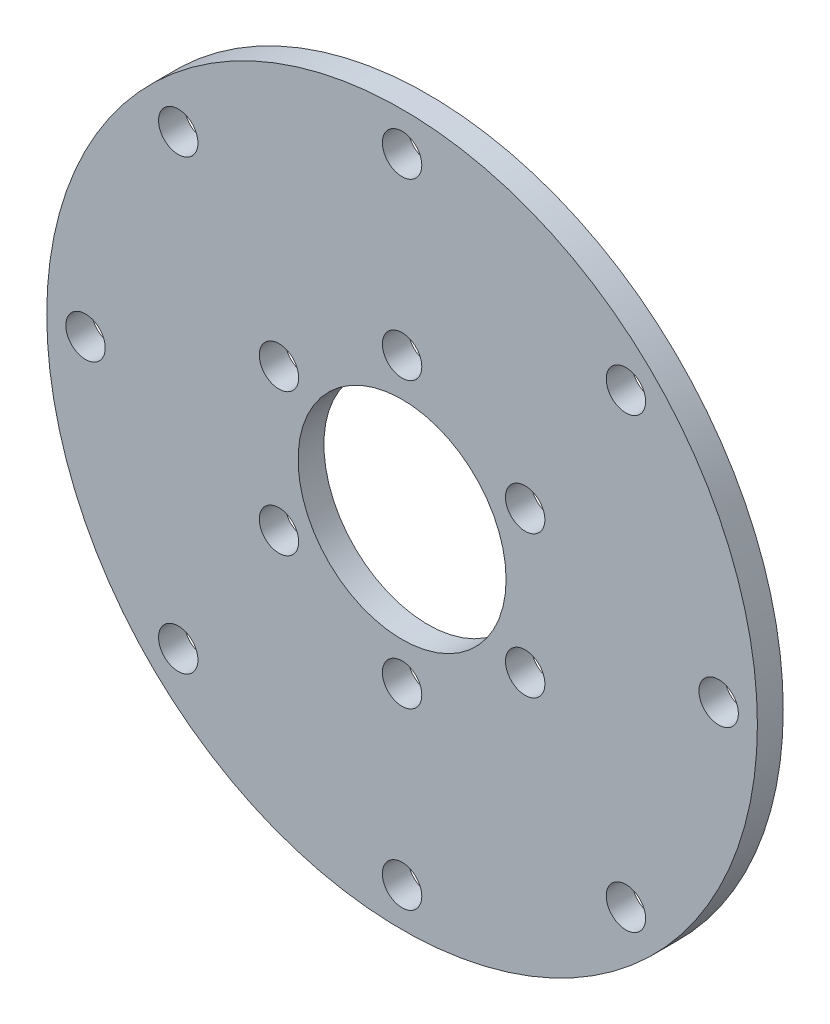
from build123d import *

# Parameters (mm, degrees)
SKETCH_1_R          = 27.5
SKETCH_1_R_2        = 8.05
EXTRUDE_1_DEPTH     = 2
SKETCH_2_R          = 1.525
CUT_EXTRUDE_1_DEPTH = 2
SKETCH_3_R          = 1.525
CUT_EXTRUDE_2_DEPTH = 2


with BuildPart() as part:
    # 草图1 → 凸台-拉伸1 (new body)
    with BuildSketch(Plane.XY):
        Circle(SKETCH_1_R)
        Circle(SKETCH_1_R_2, mode=Mode.SUBTRACT)
    extrude(amount=EXTRUDE_1_DEPTH)

    # 草图2 → 切除-拉伸1 (cut)
    with BuildSketch(Plane.XY.offset(2)):
        with Locations((0, 11)):
            Circle(SKETCH_2_R)
        with Locations((9.526279442, 5.5)):
            Circle(SKETCH_2_R)
        with Locations((9.526279442, -5.5)):
            Circle(SKETCH_2_R)
        with Locations((0, -11)):
            Circle(SKETCH_2_R)
        with Locations((-9.526279442, -5.5)):
            Circle(SKETCH_2_R)
        with Locations((-9.526279442, 5.5)):
            Circle(SKETCH_2_R)
    extrude(amount=-CUT_EXTRUDE_1_DEPTH, mode=Mode.SUBTRACT)

    # 草图3 → 切除-拉伸2 (cut)
    with BuildSketch(Plane.XY.offset(2)):
        with Locations((0, 24.5)):
            Circle(SKETCH_3_R)
        with Locations((17.324116139, 17.324116139)):
            Circle(SKETCH_3_R)
        with Locations((24.5, 0)):
            Circle(SKETCH_3_R)
        with Locations((17.324116139, -17.324116139)):
            Circle(SKETCH_3_R)
        with Locations((0, -24.5)):
            Circle(SKETCH_3_R)
        with Locations((-17.324116139, -17.324116139)):
            Circle(SKETCH_3_R)
        with Locations((-24.5, 0)):
            Circle(SKETCH_3_R)
        with Locations((-17.324116139, 17.324116139)):
            Circle(SKETCH_3_R)
    extrude(amount=-CUT_EXTRUDE_2_DEPTH, mode=Mode.SUBTRACT)


solid = part.part
